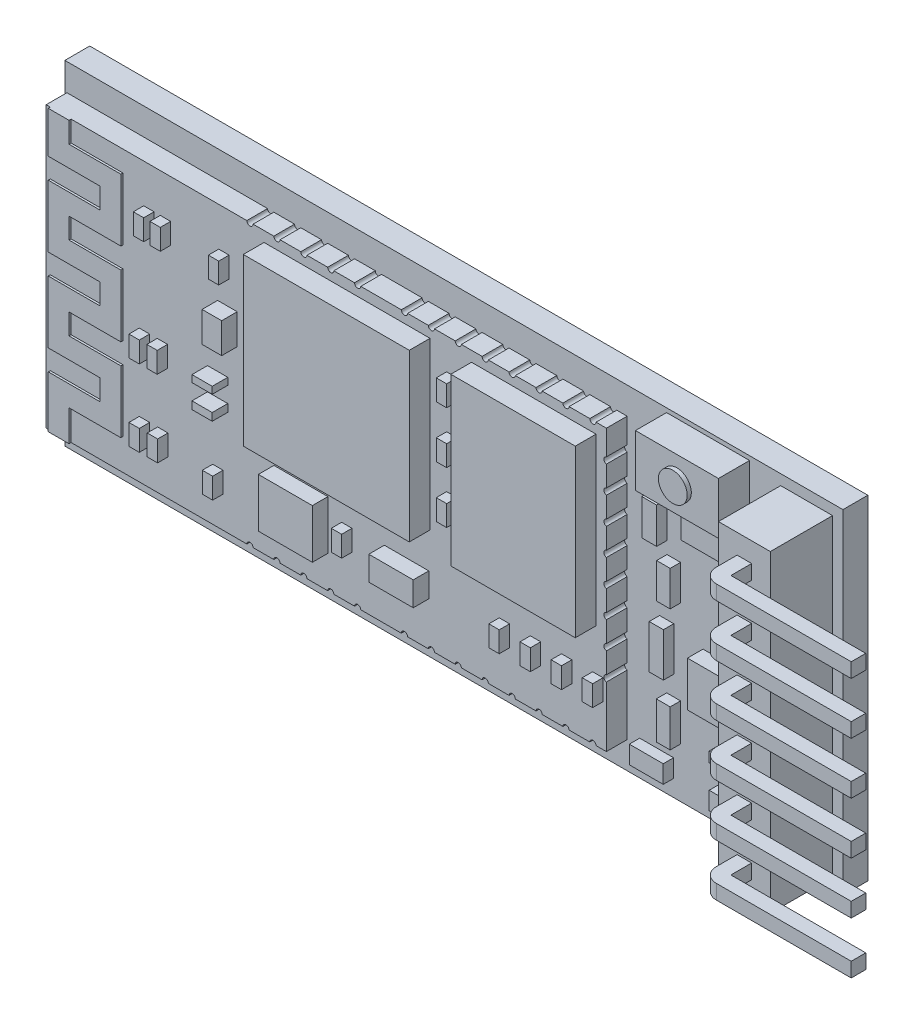
from build123d import *

# Parameters (mm, degrees)
IZIM2_W                       = 37.5
IZIM2_H                       = 16.1
Y_KSEKLIK_EKSTR_ZYON1_DEPTH   = 1.2
IZIM5_W                       = 2.5
IZIM5_H                       = 15.1
Y_KSEKLIK_EKSTR_ZYON2_DEPTH   = 3
IZIM6_W                       = 0.7
IZIM6_H                       = 0.7
Y_KSEKLIK_EKSTR_ZYON3_DEPTH   = 1
Y_KSEKLIK_EKSTR_ZYON3_2_DEPTH = 1
Y_KSEKLIK_EKSTR_ZYON3_3_DEPTH = 1
Y_KSEKLIK_EKSTR_ZYON3_4_DEPTH = 1
Y_KSEKLIK_EKSTR_ZYON3_5_DEPTH = 1
Y_KSEKLIK_EKSTR_ZYON3_6_DEPTH = 1
Y_KSEKLIK_EKSTR_ZYON4_DEPTH   = 0.7
Y_KSEKLIK_EKSTR_ZYON5_DEPTH   = 0.7
Y_KSEKLIK_EKSTR_ZYON6_DEPTH   = 0.7
Y_KSEKLIK_EKSTR_ZYON7_DEPTH   = 0.7
Y_KSEKLIK_EKSTR_ZYON8_DEPTH   = 0.7
Y_KSEKLIK_EKSTR_ZYON9_DEPTH   = 0.7
IZIM14_W                      = 27
IZIM14_H                      = 13.5
Y_KSEKLIK_EKSTR_ZYON10_DEPTH  = 1
Y_KSEKLIK_EKSTR_ZYON11_DEPTH  = 0.1
IZIM16_W                      = 4
IZIM16_H                      = 2.5
Y_KSEKLIK_EKSTR_ZYON12_DEPTH  = 1.5
IZIM17_R                      = 0.693604575
Y_KSEKLIK_EKSTR_ZYON13_DEPTH  = 0.2
IZIM18_W                      = 6
IZIM18_H                      = 8
IZIM18_W_2                    = 8
Y_KSEKLIK_EKSTR_ZYON14_DEPTH  = 1
IZIM19_W                      = 0.5
IZIM19_H                      = 1
Y_KSEKLIK_EKSTR_ZYON15_DEPTH  = 0.5
IZIM22_W                      = 0.5
IZIM22_H                      = 1
Y_KSEKLIK_EKSTR_ZYON17_DEPTH  = 0.5
IZIM23_W                      = 2.602430281
IZIM23_H                      = 2.367545487
IZIM23_W_2                    = 2.141321068
IZIM23_H_2                    = 1.16646021
IZIM23_W_3                    = 0.976073465
IZIM23_H_3                    = 0.365909355
IZIM23_H_4                    = 0.334632026
IZIM23_W_4                    = 0.943360629
IZIM23_H_5                    = 1.46024084
Y_KSEKLIK_EKSTR_ZYON18_DEPTH  = 0.75
IZIM24_W                      = 2.706810909
IZIM24_H                      = 1.742911909
IZIM24_W_2                    = 0.716474489
IZIM24_H_2                    = 1.726632447
IZIM24_W_3                    = 0.652791749
IZIM24_H_3                    = 1.693765047
IZIM24_W_4                    = 0.684633119
IZIM24_H_4                    = 2.106353334
IZIM24_W_5                    = 0.668712434
IZIM24_H_5                    = 1.80079444
IZIM24_W_6                    = 1.634021616
IZIM24_H_6                    = 0.862411809
IZIM24_W_7                    = 1.353405455
IZIM24_H_7                    = 0.499412084
IZIM24_W_8                    = 1.368285393
IZIM24_H_8                    = 0.823617913
IZIM24_H_9                    = 0.791721171
Y_KSEKLIK_EKSTR_ZYON19_DEPTH  = 0.5
IZIM25_W                      = 3.051168615
IZIM25_H                      = 2.165639046
Y_KSEKLIK_EKSTR_ZYON20_DEPTH  = 0.75
KES_EKSTR_ZYON1_DEPTH         = 1
KES_EKSTR_ZYON2_DEPTH         = 1


with BuildPart() as part:
    # Çizim2 → Yükseklik-Ekstrüzyon1 (new body)
    with BuildSketch(Plane.XY):
        with Locations((18.75, 8.05)):
            Rectangle(IZIM2_W, IZIM2_H)
    extrude(amount=Y_KSEKLIK_EKSTR_ZYON1_DEPTH)

    # Çizim5 → Yükseklik-Ekstrüzyon2 (add)
    with BuildSketch(Plane.XY.offset(1.2)):
        with Locations((35.75, 8.05)):
            Rectangle(IZIM5_W, IZIM5_H)
    extrude(amount=Y_KSEKLIK_EKSTR_ZYON2_DEPTH)

    # Çizim14 → Yükseklik-Ekstrüzyon10 (add)
    with BuildSketch(Plane.XY.offset(1.2)):
        with Locations((13.6, 8.05)):
            Rectangle(IZIM14_W, IZIM14_H)
    extrude(amount=Y_KSEKLIK_EKSTR_ZYON10_DEPTH)

    # Çizim15 → Yükseklik-Ekstrüzyon11 (add)
    with BuildSketch(Plane.XY.offset(2.2)):
        Polygon((0.3, 1.3), (0.3, 3.8), (2.8, 3.8), (2.8, 4.8), (0.3, 4.8), (0.3, 7.8), (2.8, 7.8), (2.8, 8.8), (0.3, 8.8), (0.3, 11.8), (2.8, 11.8), (2.8, 12.8), (0.3, 12.8), (0.3, 14.8), (1.3, 14.8), (1.3, 13.8), (3.8, 13.8), (3.8, 10.8), (1.3, 10.8), (1.3, 9.8), (3.8, 9.8), (3.8, 6.8), (1.3, 6.8), (1.3, 5.8), (3.8, 5.8), (3.8, 2.8), (1.3, 2.8), (1.3, 1.3), align=None)
    extrude(amount=Y_KSEKLIK_EKSTR_ZYON11_DEPTH)



with BuildPart() as body_2:
    # Çizim6 → Yükseklik-Ekstrüzyon3 (new body)
    with BuildSketch(Plane.XY.offset(4.2)):
        with Locations((35.75, 1.8)):
            Rectangle(IZIM6_W, IZIM6_H)
    extrude(amount=Y_KSEKLIK_EKSTR_ZYON3_DEPTH)

    # Çizim8 → Yükseklik-Ekstrüzyon4 (add)
    with BuildSketch(Plane.XZ.offset(-1.45)):
        with BuildLine():
            Line((36.1, 5.2), (42.6, 5.2))
            Line((42.6, 5.2), (42.6, 5.9))
            Line((42.6, 5.9), (36.1, 5.9))
            ThreePointArc((36.1, 5.9), (35.605025253, 5.694974747), (35.4, 5.2))
            Line((35.4, 5.2), (36.1, 5.2))
        make_face()
    extrude(amount=-Y_KSEKLIK_EKSTR_ZYON4_DEPTH)


with BuildPart() as body_3:
    # Çizim6 → Y_kseklik-Ekstr_zyon3 2 (new body)
    with BuildSketch(Plane.XY.offset(4.2)):
        with Locations((35.75, 4.3)):
            Rectangle(IZIM6_W, IZIM6_H)
    extrude(amount=Y_KSEKLIK_EKSTR_ZYON3_2_DEPTH)

    # Çizim9 → Yükseklik-Ekstrüzyon5 (add)
    with BuildSketch(Plane.XZ.offset(-3.95)):
        with BuildLine():
            Line((36.1, 5.2), (42.6, 5.2))
            Line((42.6, 5.2), (42.6, 5.9))
            Line((42.6, 5.9), (36.1, 5.9))
            ThreePointArc((36.1, 5.9), (35.605025253, 5.694974747), (35.4, 5.2))
            Line((35.4, 5.2), (36.1, 5.2))
        make_face()
    extrude(amount=-Y_KSEKLIK_EKSTR_ZYON5_DEPTH)


with BuildPart() as body_4:
    # Çizim6 → Y_kseklik-Ekstr_zyon3 3 (new body)
    with BuildSketch(Plane.XY.offset(4.2)):
        with Locations((35.75, 9.3)):
            Rectangle(IZIM6_W, IZIM6_H)
    extrude(amount=Y_KSEKLIK_EKSTR_ZYON3_3_DEPTH)

    # Çizim11 → Yükseklik-Ekstrüzyon7 (add)
    with BuildSketch(Plane.XZ.offset(-8.95)):
        with BuildLine():
            Line((36.1, 5.2), (42.6, 5.2))
            Line((42.6, 5.2), (42.6, 5.9))
            Line((42.6, 5.9), (36.1, 5.9))
            ThreePointArc((36.1, 5.9), (35.605025253, 5.694974747), (35.4, 5.2))
            Line((35.4, 5.2), (36.1, 5.2))
        make_face()
    extrude(amount=-Y_KSEKLIK_EKSTR_ZYON7_DEPTH)


with BuildPart() as body_5:
    # Çizim6 → Y_kseklik-Ekstr_zyon3 4 (new body)
    with BuildSketch(Plane.XY.offset(4.2)):
        with Locations((35.75, 11.8)):
            Rectangle(IZIM6_W, IZIM6_H)
    extrude(amount=Y_KSEKLIK_EKSTR_ZYON3_4_DEPTH)

    # Çizim12 → Yükseklik-Ekstrüzyon8 (add)
    with BuildSketch(Plane.XZ.offset(-11.45)):
        with BuildLine():
            Line((36.1, 5.2), (42.6, 5.2))
            Line((42.6, 5.2), (42.6, 5.9))
            Line((42.6, 5.9), (36.1, 5.9))
            ThreePointArc((36.1, 5.9), (35.605025253, 5.694974747), (35.4, 5.2))
            Line((35.4, 5.2), (36.1, 5.2))
        make_face()
    extrude(amount=-Y_KSEKLIK_EKSTR_ZYON8_DEPTH)


with BuildPart() as body_6:
    # Çizim6 → Y_kseklik-Ekstr_zyon3 5 (new body)
    with BuildSketch(Plane.XY.offset(4.2)):
        with Locations((35.75, 14.3)):
            Rectangle(IZIM6_W, IZIM6_H)
    extrude(amount=Y_KSEKLIK_EKSTR_ZYON3_5_DEPTH)

    # Çizim13 → Yükseklik-Ekstrüzyon9 (add)
    with BuildSketch(Plane.XZ.offset(-13.95)):
        with BuildLine():
            Line((36.1, 5.2), (42.6, 5.2))
            Line((42.6, 5.2), (42.6, 5.9))
            Line((42.6, 5.9), (36.1, 5.9))
            ThreePointArc((36.1, 5.9), (35.605025253, 5.694974747), (35.4, 5.2))
            Line((35.4, 5.2), (36.1, 5.2))
        make_face()
    extrude(amount=-Y_KSEKLIK_EKSTR_ZYON9_DEPTH)


with BuildPart() as body_7:
    # Çizim6 → Y_kseklik-Ekstr_zyon3 6 (new body)
    with BuildSketch(Plane.XY.offset(4.2)):
        with Locations((35.75, 6.8)):
            Rectangle(IZIM6_W, IZIM6_H)
    extrude(amount=Y_KSEKLIK_EKSTR_ZYON3_6_DEPTH)

    # Çizim10 → Yükseklik-Ekstrüzyon6 (add)
    with BuildSketch(Plane.XZ.offset(-6.45)):
        with BuildLine():
            Line((36.1, 5.2), (42.6, 5.2))
            Line((42.6, 5.2), (42.6, 5.9))
            Line((42.6, 5.9), (36.1, 5.9))
            ThreePointArc((36.1, 5.9), (35.605025253, 5.694974747), (35.4, 5.2))
            Line((35.4, 5.2), (36.1, 5.2))
        make_face()
    extrude(amount=-Y_KSEKLIK_EKSTR_ZYON6_DEPTH)


with BuildPart() as body_8:
    # Çizim16 → Yükseklik-Ekstrüzyon12 (new body)
    with BuildSketch(Plane.XY.offset(1.2)):
        with Locations((31, 14.65)):
            Rectangle(IZIM16_W, IZIM16_H)
    extrude(amount=Y_KSEKLIK_EKSTR_ZYON12_DEPTH)


with BuildPart() as part_1:
    add(part.part)

    add(body_8.part)  # Yükseklik-Ekstrüzyon13 merges body 8
    # Çizim17 → Yükseklik-Ekstrüzyon13 (add)
    with BuildSketch(Plane.XY.offset(2.7)):
        with Locations((31, 14.65)):
            Circle(IZIM17_R)
    extrude(amount=Y_KSEKLIK_EKSTR_ZYON13_DEPTH)

    # Çizim18 → Yükseklik-Ekstrüzyon14 (add)
    with BuildSketch(Plane.XY.offset(2.2)):
        with Locations((23.600429337, 10.3)):
            Rectangle(IZIM18_W, IZIM18_H)
        with Locations((14.600429337, 10.3)):
            Rectangle(IZIM18_W_2, IZIM18_H)
    extrude(amount=Y_KSEKLIK_EKSTR_ZYON14_DEPTH)

    # Çizim19 → Yükseklik-Ekstrüzyon15 (add)
    with BuildSketch(Plane.XY.offset(2.2)):
        with Locations((5.05, 12.430030241)):
            Rectangle(IZIM19_W, IZIM19_H)
        with Locations((5.85, 12.430030241)):
            Rectangle(IZIM19_W, IZIM19_H)
        with Locations((8.665669621, 12.430030241)):
            Rectangle(IZIM19_W, IZIM19_H)
    extrude(amount=Y_KSEKLIK_EKSTR_ZYON15_DEPTH)

    # Çizim22 → Yükseklik-Ekstrüzyon17 (add)
    with BuildSketch(Plane.XY.offset(2.2)):
        with Locations((4.838962256, 7.221997086)):
            Rectangle(IZIM22_W, IZIM22_H)
        with Locations((5.701638758, 7.221997086)):
            Rectangle(IZIM22_W, IZIM22_H)
        with Locations((4.838818901, 3.533540421)):
            Rectangle(IZIM22_W, IZIM22_H)
        with Locations((5.720100061, 3.533540421)):
            Rectangle(IZIM22_W, IZIM22_H)
        with Locations((8.374321984, 3.306212795)):
            Rectangle(IZIM22_W, IZIM22_H)
        with Locations((19.650429337, 12.8)):
            Rectangle(IZIM22_W, IZIM22_H)
        with Locations((19.650429337, 10.3)):
            Rectangle(IZIM22_W, IZIM22_H)
        with Locations((19.650429337, 7.8)):
            Rectangle(IZIM22_W, IZIM22_H)
        with Locations((26.685091813, 3.8)):
            Rectangle(IZIM22_W, IZIM22_H)
        with Locations((25.185091813, 3.8)):
            Rectangle(IZIM22_W, IZIM22_H)
        with Locations((23.685091813, 3.8)):
            Rectangle(IZIM22_W, IZIM22_H)
        with Locations((22.185091813, 3.8)):
            Rectangle(IZIM22_W, IZIM22_H)
        with Locations((14.590448244, 3.990810695)):
            Rectangle(IZIM22_W, IZIM22_H)
    extrude(amount=Y_KSEKLIK_EKSTR_ZYON17_DEPTH)

    # Çizim23 → Yükseklik-Ekstrüzyon18 (add)
    with BuildSketch(Plane.XY.offset(2.2)):
        with Locations((12.376318164, 4.047967675)):
            Rectangle(IZIM23_W, IZIM23_H)
        with Locations((17.469520012, 3.979476737)):
            Rectangle(IZIM23_W_2, IZIM23_H_2)
        with Locations((8.364147087, 6.520171395)):
            Rectangle(IZIM23_W_3, IZIM23_H_3)
        with Locations((8.364147087, 7.631045899)):
            Rectangle(IZIM23_W_3, IZIM23_H_4)
        with Locations((8.835827401, 10.033036523)):
            Rectangle(IZIM23_W_4, IZIM23_H_5)
    extrude(amount=Y_KSEKLIK_EKSTR_ZYON18_DEPTH)

    # Çizim24 → Yükseklik-Ekstrüzyon19 (add)
    with BuildSketch(Plane.XY.offset(1.2)):
        with Locations((31.553494099, 12.29905928)):
            Rectangle(IZIM24_W, IZIM24_H)
        with Locations((28.662605916, 11.435743057)):
            Rectangle(IZIM24_W_2, IZIM24_H_2)
        with Locations((29.347239034, 9.137191125)):
            Rectangle(IZIM24_W_3, IZIM24_H_3)
        with Locations((29.004922476, 6.207999371)):
            Rectangle(IZIM24_W_4, IZIM24_H_4)
        with Locations((29.339278692, 3.303381049)):
            Rectangle(IZIM24_W_5, IZIM24_H_5)
        with Locations((28.522267884, 1.231924795)):
            Rectangle(IZIM24_W_6, IZIM24_H_6)
        with Locations((32.230196826, 1.231924795)):
            Rectangle(IZIM24_W_7, IZIM24_H_6)
        with Locations((32.230196826, 3.053675007)):
            Rectangle(IZIM24_W_7, IZIM24_H_7)
        with Locations((32.704361967, 10.395882605)):
            Rectangle(IZIM24_W_8, IZIM24_H_8)
        with Locations((32.704361967, 8.686169187)):
            Rectangle(IZIM24_W_8, IZIM24_H_9)
    extrude(amount=Y_KSEKLIK_EKSTR_ZYON19_DEPTH)

    # Çizim25 → Yükseklik-Ekstrüzyon20 (add)
    with BuildSketch(Plane.XY.offset(1.2)):
        with Locations((32.282514113, 5.823350592)):
            Rectangle(IZIM25_W, IZIM25_H)
    extrude(amount=Y_KSEKLIK_EKSTR_ZYON20_DEPTH)

    # Çizim27 → Kes-Ekstrüzyon1 (cut)
    with BuildSketch(Plane.XY.offset(2.2)):
        with BuildLine():
            Line((26.6, 14.8), (26.3, 14.8))
            ThreePointArc((26.3, 14.8), (26.45, 14.65), (26.6, 14.8))
        make_face()
        with BuildLine():
            Line((25.3, 14.8), (25.004468137, 14.8))
            ThreePointArc((25.004468137, 14.8), (25.152234068, 14.652234068), (25.3, 14.8))
        make_face()
        with BuildLine():
            Line((23.708936273, 14.8), (24.004468137, 14.8))
            ThreePointArc((24.004468137, 14.8), (23.856702205, 14.652234068), (23.708936273, 14.8))
        make_face()
        with BuildLine():
            Line((22.408936273, 14.8), (22.708936273, 14.8))
            ThreePointArc((22.708936273, 14.8), (22.558936273, 14.65), (22.408936273, 14.8))
        make_face()
        with BuildLine():
            Line((21.408936273, 14.8), (21.108936273, 14.8))
            ThreePointArc((21.108936273, 14.8), (21.258936273, 14.65), (21.408936273, 14.8))
        make_face()
        with BuildLine():
            Line((20.108936273, 14.8), (19.81340441, 14.8))
            ThreePointArc((19.81340441, 14.8), (19.961170341, 14.652234068), (20.108936273, 14.8))
        make_face()
        with BuildLine():
            Line((18.517872546, 14.8), (18.81340441, 14.8))
            ThreePointArc((18.81340441, 14.8), (18.665638478, 14.652234068), (18.517872546, 14.8))
        make_face()
        with BuildLine():
            Line((17.217872546, 14.8), (17.517872546, 14.8))
            ThreePointArc((17.517872546, 14.8), (17.367872546, 14.65), (17.217872546, 14.8))
        make_face()
        with BuildLine():
            Line((15.261871651, 14.8), (14.961871651, 14.8))
            ThreePointArc((14.961871651, 14.8), (15.111871651, 14.65), (15.261871651, 14.8))
        make_face()
        with BuildLine():
            Line((13.961871651, 14.8), (13.666339787, 14.8))
            ThreePointArc((13.666339787, 14.8), (13.814105719, 14.652234068), (13.961871651, 14.8))
        make_face()
        with BuildLine():
            Line((12.370807924, 14.8), (12.666339787, 14.8))
            ThreePointArc((12.666339787, 14.8), (12.518573856, 14.652234068), (12.370807924, 14.8))
        make_face()
        with BuildLine():
            Line((11.070807924, 14.8), (11.370807924, 14.8))
            ThreePointArc((11.370807924, 14.8), (11.220807924, 14.65), (11.070807924, 14.8))
        make_face()
        with BuildLine():
            Line((10.070807924, 14.8), (9.770807924, 14.8))
            ThreePointArc((9.770807924, 14.8), (9.920807924, 14.65), (10.070807924, 14.8))
        make_face()
        with BuildLine():
            Line((10.070807924, 1.3), (9.770807924, 1.3))
            ThreePointArc((9.770807924, 1.3), (9.920807924, 1.45), (10.070807924, 1.3))
        make_face()
        with BuildLine():
            Line((11.070807924, 1.3), (11.370807924, 1.3))
            ThreePointArc((11.370807924, 1.3), (11.220807924, 1.45), (11.070807924, 1.3))
        make_face()
        with BuildLine():
            Line((12.370807924, 1.3), (12.666339787, 1.3))
            ThreePointArc((12.666339787, 1.3), (12.518573856, 1.447765932), (12.370807924, 1.3))
        make_face()
        with BuildLine():
            Line((13.961871651, 1.3), (13.666339787, 1.3))
            ThreePointArc((13.666339787, 1.3), (13.814105719, 1.447765932), (13.961871651, 1.3))
        make_face()
        with BuildLine():
            Line((15.261871651, 1.3), (14.961871651, 1.3))
            ThreePointArc((14.961871651, 1.3), (15.111871651, 1.45), (15.261871651, 1.3))
        make_face()
        with BuildLine():
            Line((17.217872546, 1.3), (17.517872546, 1.3))
            ThreePointArc((17.517872546, 1.3), (17.367872546, 1.45), (17.217872546, 1.3))
        make_face()
        with BuildLine():
            Line((18.517872546, 1.3), (18.81340441, 1.3))
            ThreePointArc((18.81340441, 1.3), (18.665638478, 1.447765932), (18.517872546, 1.3))
        make_face()
        with BuildLine():
            Line((20.108936273, 1.3), (19.81340441, 1.3))
            ThreePointArc((19.81340441, 1.3), (19.961170341, 1.447765932), (20.108936273, 1.3))
        make_face()
        with BuildLine():
            Line((21.408936273, 1.3), (21.108936273, 1.3))
            ThreePointArc((21.108936273, 1.3), (21.258936273, 1.45), (21.408936273, 1.3))
        make_face()
        with BuildLine():
            Line((22.408936273, 1.3), (22.708936273, 1.3))
            ThreePointArc((22.708936273, 1.3), (22.558936273, 1.45), (22.408936273, 1.3))
        make_face()
        with BuildLine():
            Line((23.708936273, 1.3), (24.004468137, 1.3))
            ThreePointArc((24.004468137, 1.3), (23.856702205, 1.447765932), (23.708936273, 1.3))
        make_face()
        with BuildLine():
            Line((25.3, 1.3), (25.004468137, 1.3))
            ThreePointArc((25.004468137, 1.3), (25.152234068, 1.447765932), (25.3, 1.3))
        make_face()
        with BuildLine():
            Line((26.6, 1.3), (26.3, 1.3))
            ThreePointArc((26.3, 1.3), (26.45, 1.45), (26.6, 1.3))
        make_face()
    extrude(amount=-KES_EKSTR_ZYON1_DEPTH, mode=Mode.SUBTRACT)

    # Çizim28 → Kes-Ekstrüzyon2 (cut)
    with BuildSketch(Plane.XY.offset(2.2)):
        with BuildLine():
            Line((27.1, 13.300479938), (27.1, 13.599833571))
            ThreePointArc((27.1, 13.599833571), (26.978735777, 13.450156754), (27.1, 13.300479938))
        make_face()
        with BuildLine():
            Line((27.1, 12.300479938), (27.1, 12.001126305))
            ThreePointArc((27.1, 12.001126305), (26.978735777, 12.150803122), (27.1, 12.300479938))
        make_face()
        with BuildLine():
            Line((27.1, 10.701772672), (27.1, 11.001126305))
            ThreePointArc((27.1, 11.001126305), (26.978735777, 10.851449489), (27.1, 10.701772672))
        make_face()
        with BuildLine():
            Line((27.1, 9.701772672), (27.1, 9.40241904))
            ThreePointArc((27.1, 9.40241904), (26.978735777, 9.552095856), (27.1, 9.701772672))
        make_face()
        with BuildLine():
            Line((27.1, 8.103065407), (27.1, 8.40241904))
            ThreePointArc((27.1, 8.40241904), (26.978735777, 8.252742223), (27.1, 8.103065407))
        make_face()
        with BuildLine():
            Line((27.1, 7.103065407), (27.1, 6.803711774))
            ThreePointArc((27.1, 6.803711774), (26.978735777, 6.953388591), (27.1, 7.103065407))
        make_face()
        with BuildLine():
            Line((27.1, 5.504358141), (27.1, 5.803711774))
            ThreePointArc((27.1, 5.803711774), (26.978735777, 5.654034958), (27.1, 5.504358141))
        make_face()
        with BuildLine():
            Line((27.1, 4.504358141), (27.1, 4.205004509))
            ThreePointArc((27.1, 4.205004509), (26.978735777, 4.354681325), (27.1, 4.504358141))
        make_face()
    extrude(amount=-KES_EKSTR_ZYON2_DEPTH, mode=Mode.SUBTRACT)


solid = Compound([body_2.part, body_3.part, body_4.part, body_5.part, body_6.part, body_7.part, part_1.part])
